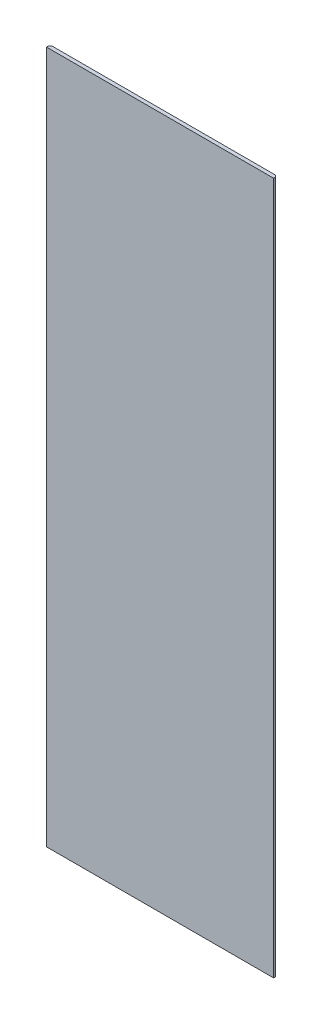
from build123d import *

# Parameters (mm, degrees)
SKETCH1_W           = 98.4125
SKETCH1_H           = 300
BOSS_EXTRUDE1_DEPTH = 0.79375
CHAMFER1_SIZE       = 0.79375


with BuildPart() as part:
    # Sketch1 → Boss-Extrude1 (new body, symmetric)
    with BuildSketch(Plane.XY):
        Rectangle(SKETCH1_W, SKETCH1_H)
    extrude(amount=BOSS_EXTRUDE1_DEPTH, both=True)

    # Chamfer1
    chamfer1_edges = [part.edges().sort_by_distance(p)[0] for p in [
        (49.20625, 0, -0.79375),
        (-49.20625, 0, -0.79375),
    ]]
    chamfer(chamfer1_edges, length=CHAMFER1_SIZE)


solid = part.part
